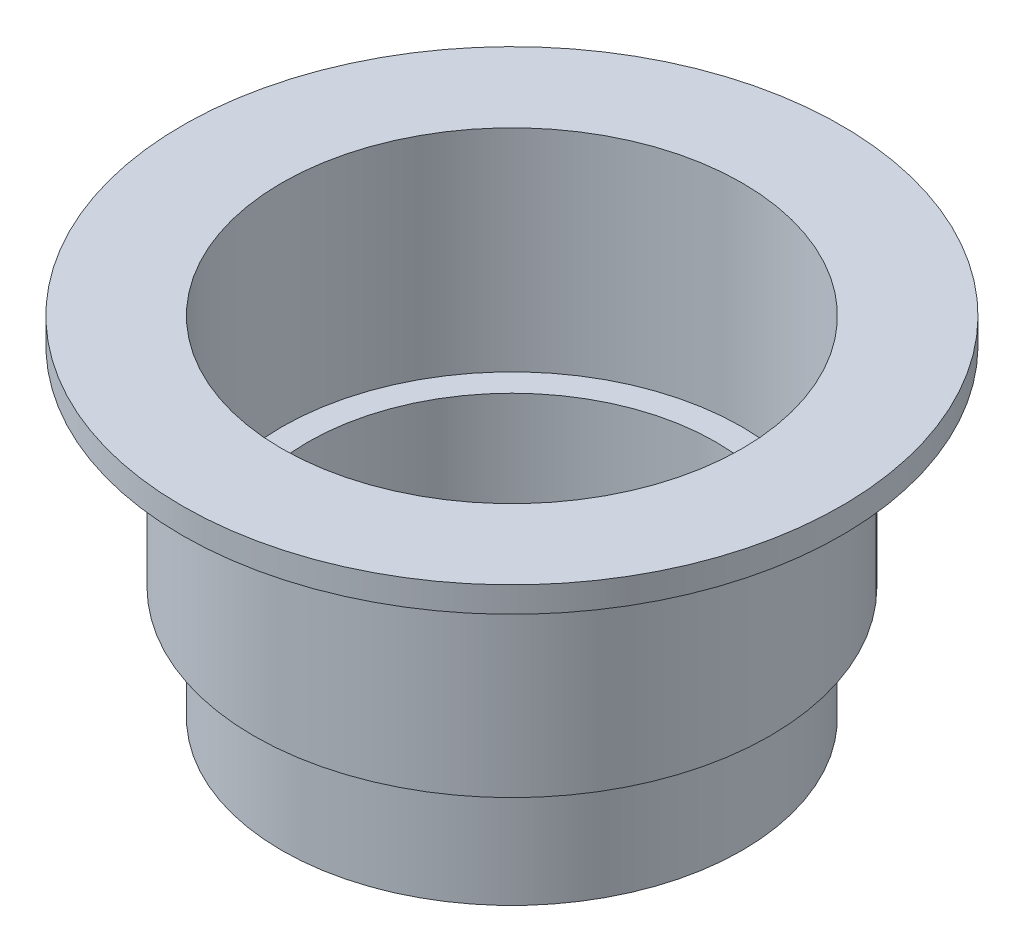
from build123d import *

# Parameters (mm, degrees)
SKETCH_2_W   = 9.5
SKETCH_2_H   = 2.44
SKETCH_2_W_2 = 19.5
SKETCH_2_H_2 = 0.1


with BuildPart() as part:
    # 草图2 → 旋转1 (revolve)
    with BuildSketch(Plane.XY):
        with Locations((26.75, -1.22)):
            Rectangle(SKETCH_2_W, SKETCH_2_H)
        Polygon((24.665, -2.44), (22, -2.44), (22, -20.2), (22, -22.45), (24.665, -22.45), align=None)
        Polygon((22, -22.45), (22, -20.2), (19.5, -20.2), (19.5, -33.16), (19.5, -33.26), (22, -33.26), align=None)
        with Locations((9.75, -33.21)):
            Rectangle(SKETCH_2_W_2, SKETCH_2_H_2)
    revolve(axis=Axis((0, 6.935540238, 0), (0, -1, 0)))


solid = part.part
